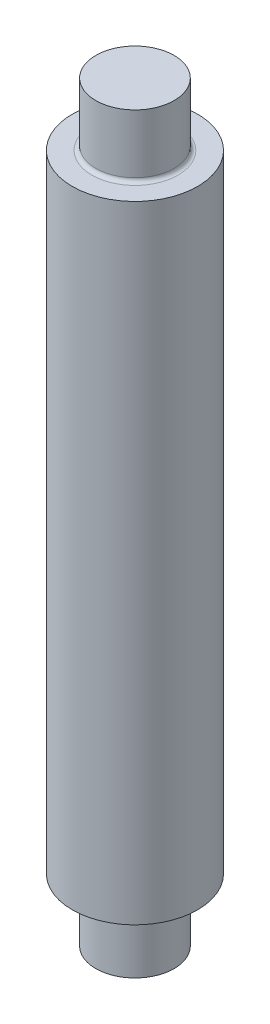
from build123d import *


with BuildPart() as part:
    # Sketch1 → Revolve1 (revolve)
    with BuildSketch(Plane.XY, mode=Mode.PRIVATE) as revolve1_sk:
        with BuildLine():
            Line((0, 76.2), (-7.9375, 76.2))
            Line((-7.9375, 76.2), (-7.9375, 64.29375))
            ThreePointArc((-7.9375, 64.29375), (-8.169983992, 63.732483992), (-8.73125, 63.5))
            Line((-8.73125, 63.5), (-12.7, 63.5))
            Line((-12.7, 63.5), (-12.7, -63.5))
            Line((-12.7, -63.5), (-8.73125, -63.5))
            ThreePointArc((-8.73125, -63.5), (-8.169983992, -63.732483992), (-7.9375, -64.29375))
            Line((-7.9375, -64.29375), (-7.9375, -76.2))
            Line((-7.9375, -76.2), (0, -76.2))
            Line((0, -76.2), (0, 76.2))
        make_face()
    revolve(revolve1_sk.sketch.rotate(Axis((0, 76.2, 0), (0, -1, 0)), 270), axis=Axis((0, 76.2, 0), (0, -1, 0)))


solid = part.part
